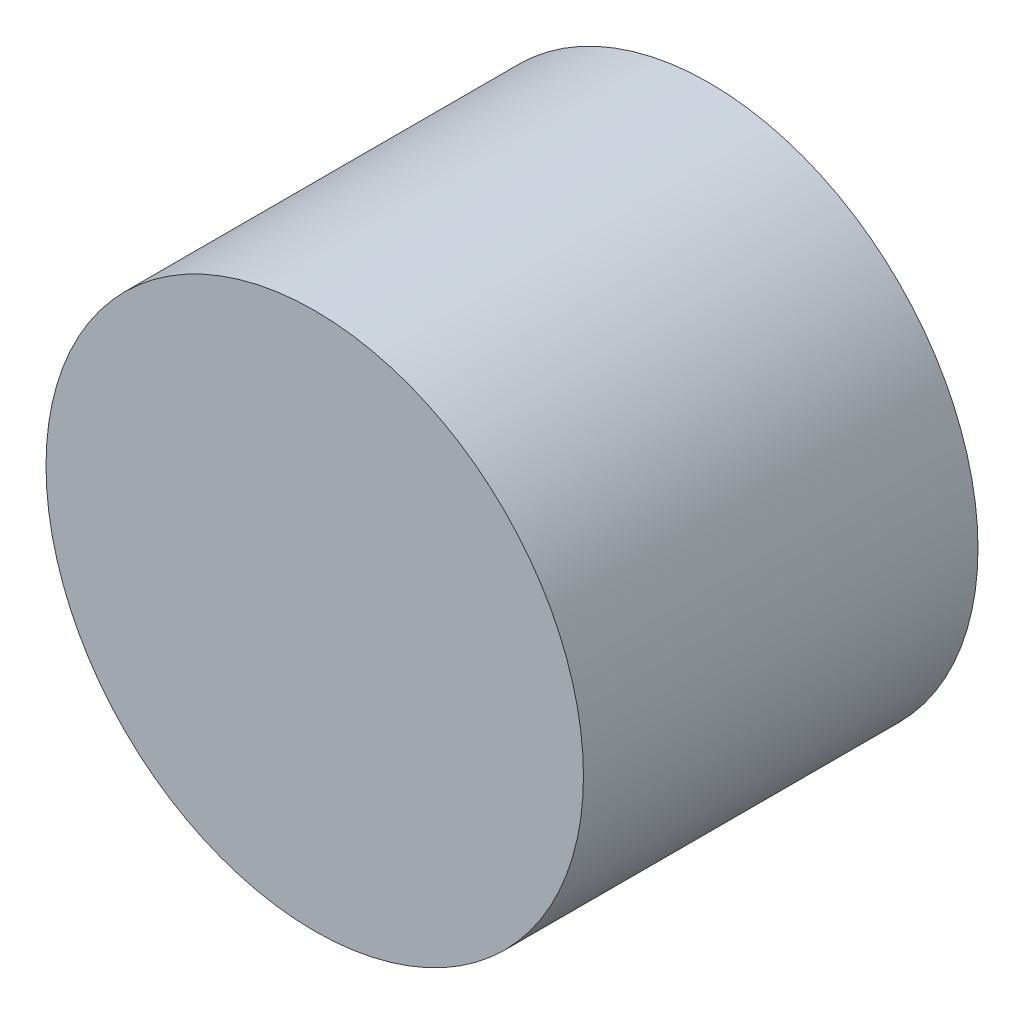
from build123d import *

# Parameters (mm, degrees)
SKETCH1_R           = 1.362304855
BOSS_EXTRUDE1_DEPTH = 2


with BuildPart() as part:
    # Sketch1 → Boss-Extrude1 (new body)
    with BuildSketch(Plane.XY):
        with Locations((4.297757617, 0)):
            Circle(SKETCH1_R)
    extrude(amount=-BOSS_EXTRUDE1_DEPTH)


solid = part.part
